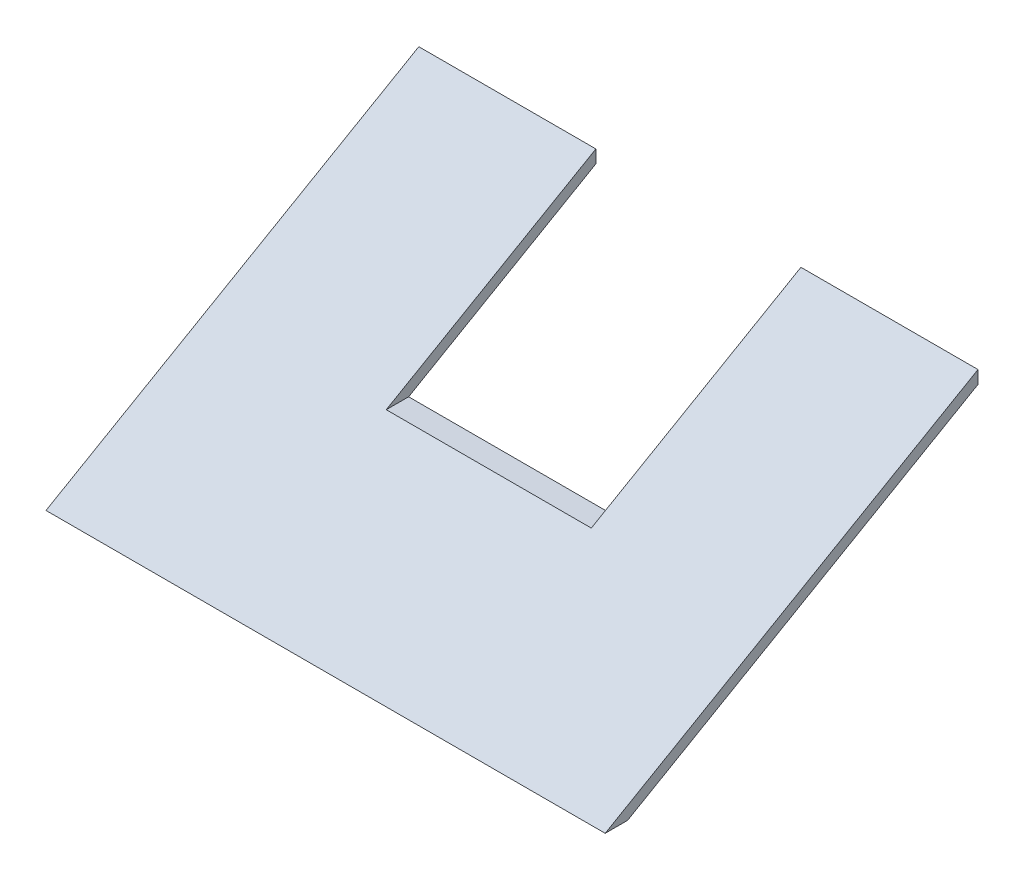
from build123d import *

# Parameters (mm, degrees)
BOSS_EXTRUDE1_DEPTH = 150
CUT_EXTRUDE1_DEPTH  = 101


with BuildPart() as part:
    # Sketch1 → Boss-Extrude1 (new body)
    with BuildSketch(Plane(origin=(0, 0, 0), x_dir=(0, 0, -1), z_dir=(1, 0, 0))):
        Polygon((0, 0), (-94, -54.270925304), (-100, -54.270925304), (0, 3.464101615), align=None)
    extrude(amount=BOSS_EXTRUDE1_DEPTH)

    # Sketch2 → Cut-Extrude1 (cut, through all)
    with BuildSketch(Plane.XY):
        Polygon((102.5, 0), (102.5, -29), (47.5, -29), (47.5, 0), (47.5, 3.464101615), (102.5, 3.464101615), align=None)
    extrude(amount=CUT_EXTRUDE1_DEPTH, mode=Mode.SUBTRACT)


solid = part.part
